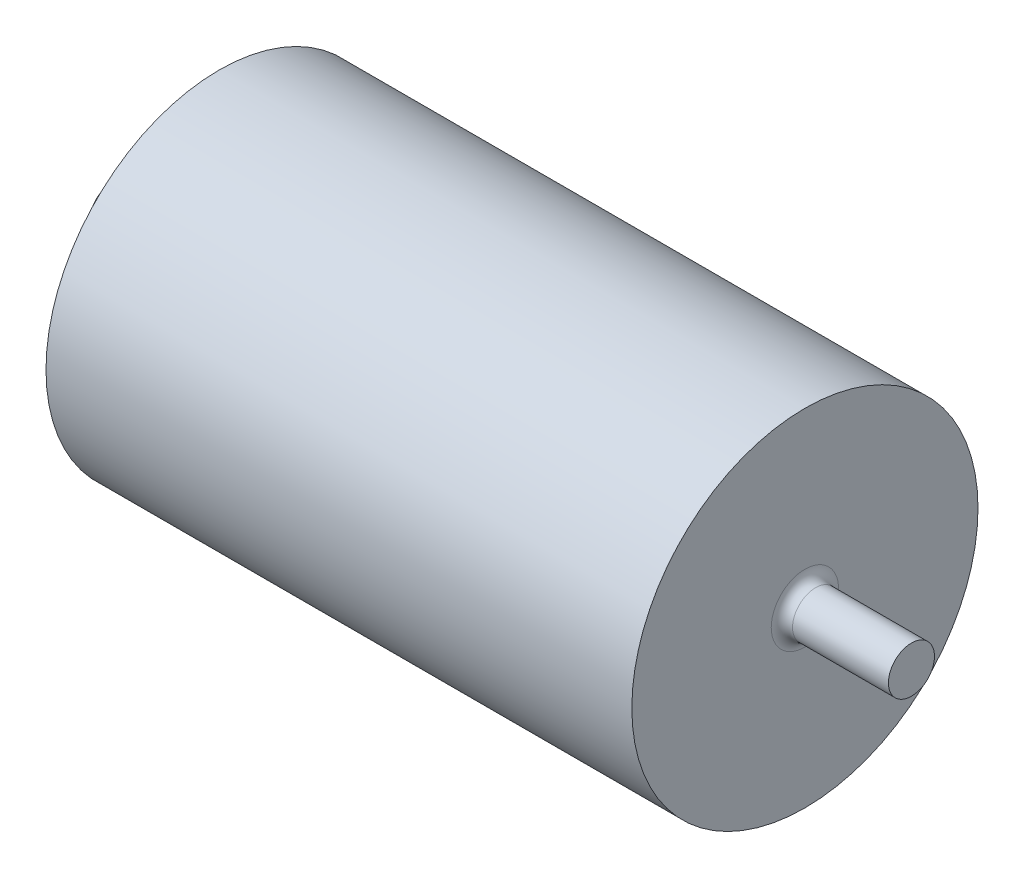
from build123d import *

# Parameters (mm, degrees)
SKETCH_1_W      = 110
SKETCH_1_H      = 32.5
SKETCH_2_R      = 4.325
EXTRUDE_1_DEPTH = 20
FILLET_1_R      = 2


with BuildPart() as part:
    # 스케치1 → 회전1 (revolve)
    with BuildSketch(Plane(origin=(0, 0, 0), x_dir=(1, 0, 0), z_dir=(0, 1, 0))):
        with Locations((0, 16.25)):
            Rectangle(SKETCH_1_W, SKETCH_1_H)
    revolve(axis=Axis((-130.174262735, 0, 0), (1, 0, 0)))

    # 스케치2 → 보스-돌출1 (add)
    with BuildSketch(Plane(origin=(55, 0, 0), x_dir=(0, 0, -1), z_dir=(1, 0, 0))):
        Circle(SKETCH_2_R)
    extrude_1 = extrude(amount=EXTRUDE_1_DEPTH)

    # 대칭 복사1: 보스-돌출1 across plane
    add(extrude_1.mirror(Plane(origin=(0, 0, 0), x_dir=(0, 0, 1), z_dir=(1, 0, 0))))

    # 필렛1
    fillet_1_edges = [part.edges().sort_by_distance(p)[0] for p in [
        (-55, 0, 4.325),
        (55, 0, 4.325),
    ]]
    fillet(fillet_1_edges, radius=FILLET_1_R)


solid = part.part
